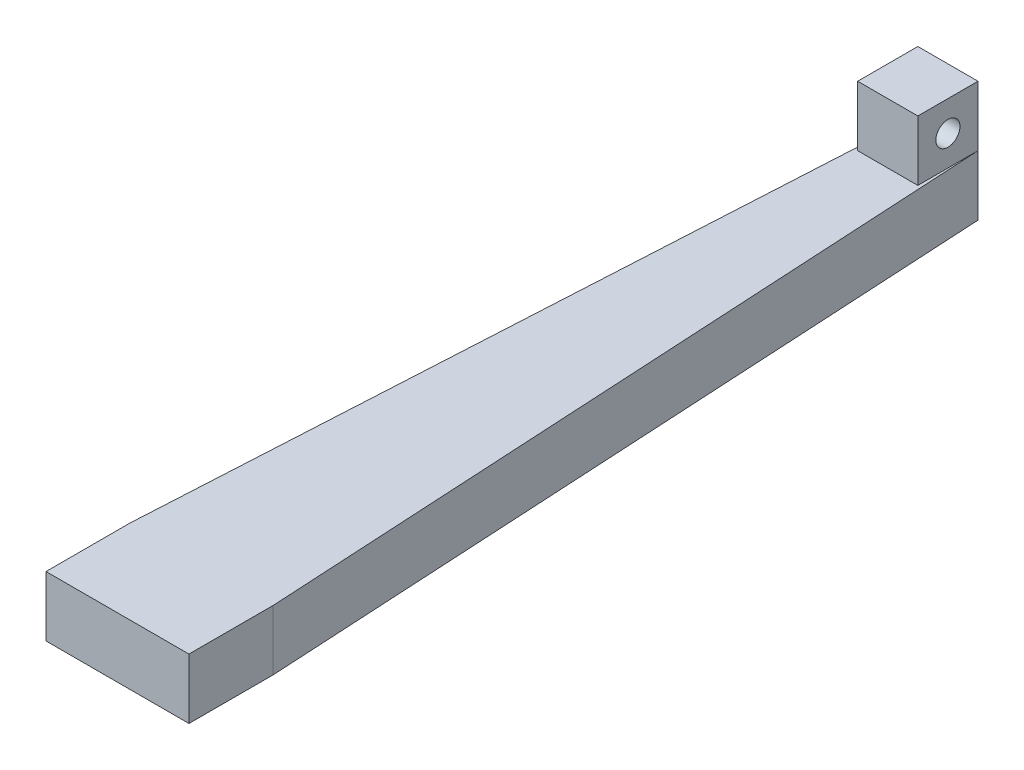
from build123d import *

# Parameters (mm, degrees)
SKETCH3_W            = 220
SKETCH3_H            = 220
BOSS_EXTRUDE1_DEPTH  = 10
CUT_EXTRUDE1_DEPTH   = 10
SKETCH5_W            = 450
SKETCH5_H            = 450
SKETCH5_W_2          = 400
SKETCH5_H_2          = 400
BOSS_EXTRUDE3_DEPTH  = 25
CUT_EXTRUDE2_DEPTH   = 25
SKETCH9_W            = 450
SKETCH9_H            = 50
CUT_EXTRUDE3_DEPTH   = 25
SKETCH10_W           = 450
SKETCH10_H           = 40
CUT_EXTRUDE4_DEPTH   = 25
SKETCH11_W           = 25
SKETCH11_H           = 25
BOSS_EXTRUDE5_DEPTH  = 25
SKETCH12_W           = 25
SKETCH12_H           = 25
BOSS_EXTRUDE6_DEPTH  = 25
SKETCH13_W           = 25
SKETCH13_H           = 25
BOSS_EXTRUDE7_DEPTH  = 25
SKETCH14_R           = 5
CUT_EXTRUDE5_DEPTH   = 25
BOSS_EXTRUDE8_DEPTH  = 25
BOSS_EXTRUDE9_DEPTH  = 25
CUT_EXTRUDE6_DEPTH   = 25
BOSS_EXTRUDE10_DEPTH = 25
BOSS_EXTRUDE11_DEPTH = 25
BOSS_EXTRUDE12_DEPTH = 400
BOSS_EXTRUDE13_DEPTH = 400
CUT_EXTRUDE7_DEPTH   = 450
SKETCH24_W           = 50
SKETCH24_H           = 59.452998038
CUT_EXTRUDE8_DEPTH   = 350
SKETCH25_W           = 25
SKETCH25_H           = 59.452998038
BOSS_EXTRUDE14_DEPTH = 35
SKETCH26_W           = 12.5
SKETCH26_H           = 172.55
BOSS_EXTRUDE15_DEPTH = 12.5
SKETCH27_W           = 12.5
SKETCH27_H           = 12.5
BOSS_EXTRUDE16_DEPTH = 12.5
SKETCH28_R           = 2.5
CUT_EXTRUDE9_DEPTH   = 12.5
SKETCH29_W           = 116.183817877
SKETCH29_H           = 120.115800598
CUT_EXTRUDE10_DEPTH  = 800


with BuildPart() as part:
    # Sketch3 → Boss-Extrude1 (new body)
    with BuildSketch(Plane(origin=(0, 0, 0), x_dir=(1, 0, 0), z_dir=(0, 1, 0))):
        Rectangle(SKETCH3_W, SKETCH3_H)
    extrude(amount=BOSS_EXTRUDE1_DEPTH)

    # Sketch4 → Cut-Extrude1 (cut)
    with BuildSketch(Plane(origin=(0, 10, 0), x_dir=(1, 0, 0), z_dir=(0, 1, 0))):
        Polygon((0, -110), (-110, 110), (-110, -110), align=None)
        Polygon((110, 110), (0, -110), (110, -110), align=None)
    extrude(amount=-CUT_EXTRUDE1_DEPTH, mode=Mode.SUBTRACT)

    # Sketch17 → Cut-Extrude6 (cut)
    with BuildSketch(Plane(origin=(0, 10, 0), x_dir=(1, 0, 0), z_dir=(0, 1, 0))):
        Polygon((-110, 110), (110, 110), (0, -110), align=None)
    extrude(amount=-CUT_EXTRUDE6_DEPTH, mode=Mode.SUBTRACT)


with BuildPart() as body_2:
    # Sketch5 → Boss-Extrude3 (new body)
    with BuildSketch(Plane.XZ):
        Rectangle(SKETCH5_W, SKETCH5_H)
        Rectangle(SKETCH5_W_2, SKETCH5_H_2, mode=Mode.SUBTRACT)
    extrude(amount=-BOSS_EXTRUDE3_DEPTH)

    # Sketch8 → Cut-Extrude2 (cut)
    with BuildSketch(Plane(origin=(0, 25, 0), x_dir=(1, 0, 0), z_dir=(0, 1, 0))):
        Polygon((-225, 200), (-200, 200), (225, 200), (225, 225), (-225, 225), align=None)
    extrude(amount=-CUT_EXTRUDE2_DEPTH, mode=Mode.SUBTRACT)

    # Sketch9 → Cut-Extrude3 (cut)
    with BuildSketch(Plane(origin=(0, 25, 0), x_dir=(1, 0, 0), z_dir=(0, 1, 0))):
        with Locations((0, 175)):
            Rectangle(SKETCH9_W, SKETCH9_H)
    extrude(amount=-CUT_EXTRUDE3_DEPTH, mode=Mode.SUBTRACT)

    # Sketch10 → Cut-Extrude4 (cut)
    with BuildSketch(Plane(origin=(0, 25, 0), x_dir=(1, 0, 0), z_dir=(0, 1, 0))):
        with Locations((0, 130)):
            Rectangle(SKETCH10_W, SKETCH10_H)
    extrude(amount=-CUT_EXTRUDE4_DEPTH, mode=Mode.SUBTRACT)

    # Sketch11 → Boss-Extrude5 (add)
    with BuildSketch(Plane(origin=(0, 0, -110), x_dir=(-1, 0, 0), z_dir=(0, 0, -1))):
        with Locations((212.5, 12.5)):
            Rectangle(SKETCH11_W, SKETCH11_H)
        with Locations((-212.5, 12.5)):
            Rectangle(SKETCH11_W, SKETCH11_H)
    extrude(amount=BOSS_EXTRUDE5_DEPTH)

    # Sketch12 → Boss-Extrude6 (add)
    with BuildSketch(Plane(origin=(-200, 0, 0), x_dir=(0, 0, -1), z_dir=(1, 0, 0))):
        with Locations((122.5, 12.5)):
            Rectangle(SKETCH12_W, SKETCH12_H)
    extrude(amount=BOSS_EXTRUDE6_DEPTH)

    # Sketch13 → Boss-Extrude7 (add)
    with BuildSketch(Plane.ZY.offset(-200)):
        with Locations((-122.5, 12.5)):
            Rectangle(SKETCH13_W, SKETCH13_H)
    extrude(amount=BOSS_EXTRUDE7_DEPTH)

    # Sketch14 → Cut-Extrude5 (cut)
    with BuildSketch(Plane(origin=(0, 25, 0), x_dir=(1, 0, 0), z_dir=(0, 1, 0))):
        with Locations(Location((-187.5, 122.5, 0), (0, 0, 270))):  # turned: the seam where the file's is
            Circle(SKETCH14_R)
        with Locations(Location((187.5, 122.5, 0), (0, 0, 270))):  # turned: the seam where the file's is
            Circle(SKETCH14_R)
    extrude(amount=-CUT_EXTRUDE5_DEPTH, mode=Mode.SUBTRACT)

    # Sketch15 → Boss-Extrude8 (add)
    with BuildSketch(Plane.ZY.offset(225)):
        Polygon((225, 0), (225, -20), (-135, 0), align=None)
        Polygon((225, 25), (225, 45), (-135, 25), align=None)
    extrude(amount=-BOSS_EXTRUDE8_DEPTH)

    # Sketch16 → Boss-Extrude9 (add)
    with BuildSketch(Plane(origin=(225, 0, 0), x_dir=(0, 0, -1), z_dir=(1, 0, 0))):
        Polygon((-225, 45), (-225, 25), (135, 25), align=None)
        Polygon((-225, 0), (-225, -20), (135, 0), align=None)
    extrude(amount=-BOSS_EXTRUDE9_DEPTH)

    # Sketch18 → Boss-Extrude10 (add)
    with BuildSketch(Plane.ZY.offset(225)):
        Polygon((175.07698234, 42.226499019), (225, 45), (225, 125), align=None)
        Polygon((225, -100), (225, -20), (175.07698234, -17.226499019), align=None)
    extrude(amount=-BOSS_EXTRUDE10_DEPTH)

    # Sketch19 → Boss-Extrude11 (add)
    with BuildSketch(Plane(origin=(225, 0, 0), x_dir=(0, 0, -1), z_dir=(1, 0, 0))):
        Polygon((-225, 125), (-225, 45), (-175.07698234, 42.226499019), align=None)
        Polygon((-225, -20), (-225, -100), (-175.07698234, -17.226499019), align=None)
    extrude(amount=-BOSS_EXTRUDE11_DEPTH)

    # Sketch20 → Boss-Extrude12 (add)
    with BuildSketch(Plane(origin=(-200, 0, 0), x_dir=(0, 0, -1), z_dir=(1, 0, 0))):
        Polygon((-200, 25), (-225, 125), (-225, 25), align=None)
    extrude(amount=BOSS_EXTRUDE12_DEPTH)

    # Sketch21 → Boss-Extrude13 (add)
    with BuildSketch(Plane(origin=(-200, 0, 0), x_dir=(0, 0, -1), z_dir=(1, 0, 0))):
        Polygon((-225, 0), (-225, -100), (-200, 0), align=None)
    extrude(amount=BOSS_EXTRUDE13_DEPTH)

    # Sketch22 → Cut-Extrude7 (cut)
    with BuildSketch(Plane.ZY.offset(225)):
        Polygon((175.07698234, -17.226499019), (175.07698234, 42.226499019), (225, 125), (225, -100), align=None)
    extrude(amount=-CUT_EXTRUDE7_DEPTH, mode=Mode.SUBTRACT)

    # Sketch24 → Cut-Extrude8 (cut)
    with BuildSketch(Plane.XY.offset(175.07698234)):
        with Locations((-200, 12.5)):
            Rectangle(SKETCH24_W, SKETCH24_H)
    extrude(amount=-CUT_EXTRUDE8_DEPTH, mode=Mode.SUBTRACT)

    # Sketch25 → Boss-Extrude14 (add)
    with BuildSketch(Plane.XY.offset(175.07698234)):
        with Locations((212.5, 12.5)):
            Rectangle(SKETCH25_W, SKETCH25_H)
    extrude(amount=BOSS_EXTRUDE14_DEPTH)

    # Sketch29 → Cut-Extrude10 (cut)
    with BuildSketch(Plane.XY.offset(210.07698234)):
        with Locations((211.346821748, 11.078491342)):
            Rectangle(SKETCH29_W, SKETCH29_H)
    extrude(amount=-CUT_EXTRUDE10_DEPTH, mode=Mode.SUBTRACT)


with BuildPart() as body_2_2:
    # Sketch26 → Boss-Extrude15 (new body)
    with BuildSketch(Plane.XZ.offset(17.226499019)):
        Rectangle(SKETCH26_W, SKETCH26_H)
        Polygon((14.85, 86.275), (6.25, 86.275), (6.25, -86.275), (14.85, 68.775), align=None)
        Polygon((-14.85, 68.775), (-14.85, 86.275), (-6.25, 86.275), (-6.25, -86.275), align=None)
    extrude(amount=-BOSS_EXTRUDE15_DEPTH)

    # Sketch27 → Boss-Extrude16 (add)
    with BuildSketch(Plane(origin=(0, -4.726499019, 0), x_dir=(1, 0, 0), z_dir=(0, 1, 0))):
        with Locations((0, 80.025)):
            Rectangle(SKETCH27_W, SKETCH27_H)
    extrude(amount=BOSS_EXTRUDE16_DEPTH)

    # Sketch28 → Cut-Extrude9 (cut)
    with BuildSketch(Plane.ZY.offset(6.25)):
        with Locations((-80.025, 1.523500981)):
            Circle(SKETCH28_R)
    extrude(amount=-CUT_EXTRUDE9_DEPTH, mode=Mode.SUBTRACT)


solid = body_2_2.part
